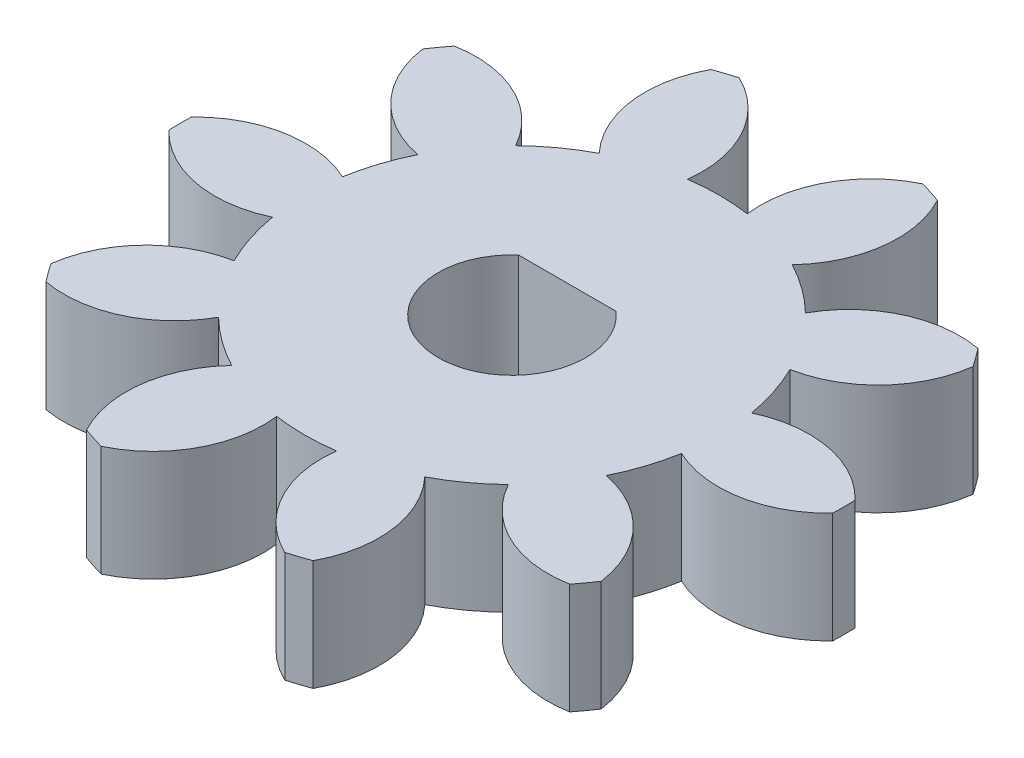
from build123d import *

# Parameters (mm, degrees)
SKETCH1_R           = 9
BOSS_EXTRUDE1_DEPTH = 3
CUT_EXTRUDE1_DEPTH  = 4
CIRPATTERN1_COUNT   = 10
CUT_EXTRUDE5_DEPTH  = 4


with BuildPart() as part:
    # Sketch1 → Boss-Extrude1 (new body)
    with BuildSketch(Plane(origin=(0, 0, 0), x_dir=(1, 0, 0), z_dir=(0, 1, 0))):
        Circle(SKETCH1_R)
    extrude(amount=BOSS_EXTRUDE1_DEPTH)

    # Sketch2 → Cut-Extrude1 (cut, through all)
    with BuildSketch(Plane(origin=(0, 3, 0), x_dir=(1, 0, 0), z_dir=(0, 1, 0))):
        with BuildLine():
            ThreePointArc((-0.810569881, 5.566291536), (0, 5.625), (0.810569881, 5.566291536))
            ThreePointArc((0.810569881, 5.566291536), (1.152028564, 7.378729724), (2.489254397, 8.648908171))
            ThreePointArc((2.489254397, 8.648908171), (0, 9), (-2.489254397, 8.648908171))
            ThreePointArc((-2.489254397, 8.648908171), (-1.152028564, 7.378729724), (-0.810569881, 5.566291536))
        make_face()
    cut_extrude1 = extrude(amount=-CUT_EXTRUDE1_DEPTH, mode=Mode.SUBTRACT)

    # CirPattern1: Cut-Extrude1 ×10 about axis
    cirpattern1_axis = Axis((0, 0, 0), (0, 1, 0))
    for i in range(1, CIRPATTERN1_COUNT):
        add(cut_extrude1.rotate(cirpattern1_axis, i * 360 / CIRPATTERN1_COUNT), mode=Mode.SUBTRACT)

    # Sketch6 → Cut-Extrude5 (cut, through all)
    with BuildSketch(Plane(origin=(0, 3, 0), x_dir=(1, 0, 0), z_dir=(0, 1, 0))):
        with BuildLine():
            Line((1.322875656, 1.5), (-1.322875656, 1.5))
            ThreePointArc((-1.322875656, 1.5), (0, -2), (1.322875656, 1.5))
        make_face()
    extrude(amount=-CUT_EXTRUDE5_DEPTH, mode=Mode.SUBTRACT)


solid = part.part
